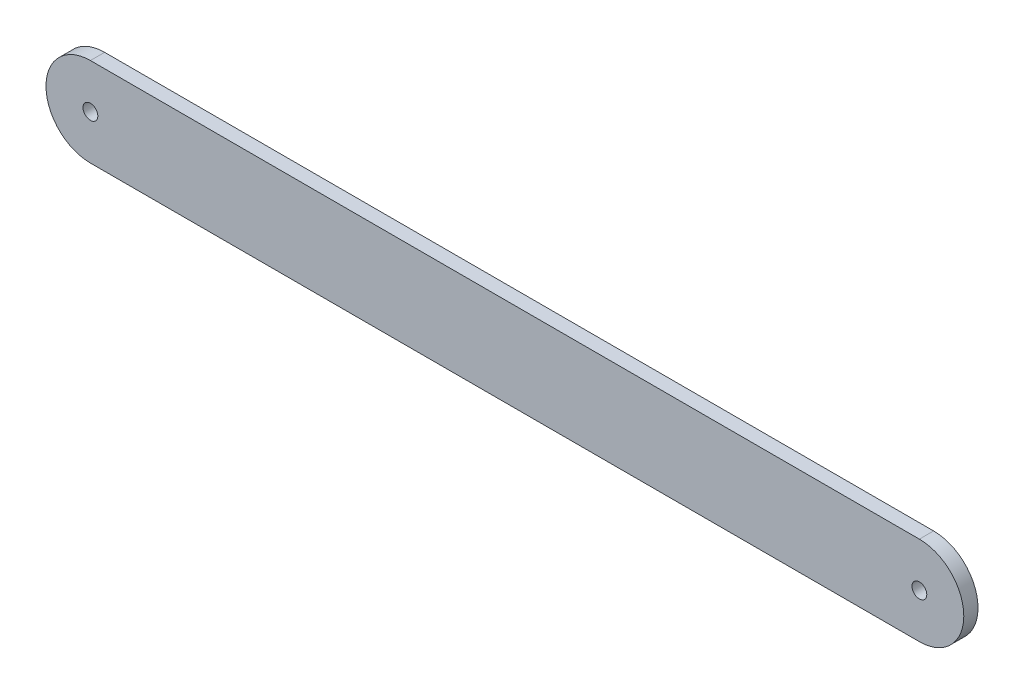
from build123d import *

# Parameters (mm, degrees)
SKETCH1_R           = 1.5875
BOSS_EXTRUDE1_DEPTH = 3.048


with BuildPart() as part:
    # Sketch1 → Boss-Extrude1 (new body)
    with BuildSketch(Plane.XY):
        with BuildLine():
            Line((0, 9.525), (177.8, 9.525))
            ThreePointArc((177.8, 9.525), (187.325, 0), (177.8, -9.525))
            Line((177.8, -9.525), (0, -9.525))
            ThreePointArc((0, -9.525), (-9.525, 0), (0, 9.525))
        make_face()
        Circle(SKETCH1_R, mode=Mode.SUBTRACT)
        with Locations((177.8, 0)):
            Circle(SKETCH1_R, mode=Mode.SUBTRACT)
    extrude(amount=BOSS_EXTRUDE1_DEPTH)


solid = part.part
